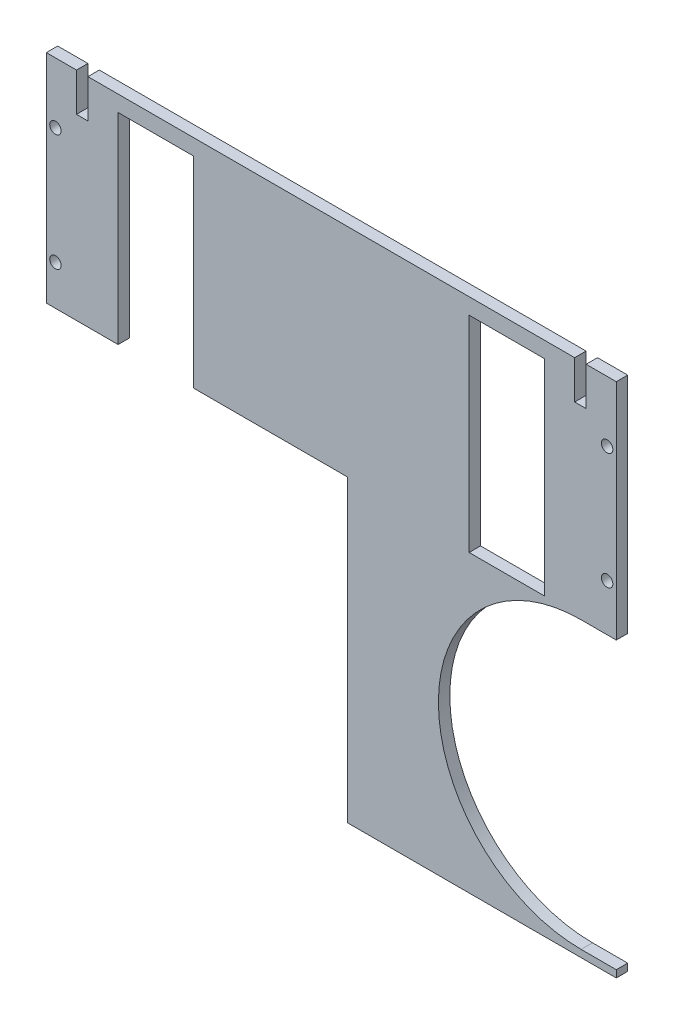
from build123d import *

# Parameters (mm, degrees)
SKETCH1_W           = 249.6
SKETCH1_H           = 267.4
SKETCH1_R           = 2.5
SKETCH1_W_2         = 33
SKETCH1_H_2         = 90
BOSS_EXTRUDE1_DEPTH = 5
CUT_EXTRUDE4_DEPTH  = 6
SKETCH7_W           = 5
SKETCH7_H           = 20
SKETCH7_H_2         = 25
CUT_EXTRUDE5_DEPTH  = 6


with BuildPart() as part:
    # Sketch1 → Boss-Extrude1 (new body)
    with BuildSketch(Plane.XY):
        with Locations((124.8, -202.7)):
            Rectangle(SKETCH1_W, SKETCH1_H)
        with Locations((245.6, -95.5)):
            Circle(SKETCH1_R, mode=Mode.SUBTRACT)
        with Locations((245.6, -146.5)):
            Circle(SKETCH1_R, mode=Mode.SUBTRACT)
        with Locations((4, -146.5)):
            Circle(SKETCH1_R, mode=Mode.SUBTRACT)
        with Locations((4, -95.5)):
            Circle(SKETCH1_R, mode=Mode.SUBTRACT)
        with Locations((201.66, -121)):
            Rectangle(SKETCH1_W_2, SKETCH1_H_2, mode=Mode.SUBTRACT)
        with Locations((47.94, -121)):
            Rectangle(SKETCH1_W_2, SKETCH1_H_2, mode=Mode.SUBTRACT)
    extrude(amount=BOSS_EXTRUDE1_DEPTH)

    # Sketch6 → Cut-Extrude4 (cut, through all)
    with BuildSketch(Plane.XY.offset(5)):
        Polygon((132, -295.148008477), (249.6, -295.148008477), (249.6, -336.4), (0, -336.4), (0, -227), (0, -164), (132, -164), align=None)
        with BuildLine():
            Line((234.205987928, -292), (296.705987928, -292))
            Line((296.705987928, -292), (296.705987928, -167))
            Line((296.705987928, -167), (234.205987928, -167))
            ThreePointArc((234.205987928, -167), (171.705987928, -229.5), (234.205987928, -292))
        make_face()
    extrude(amount=-CUT_EXTRUDE4_DEPTH, mode=Mode.SUBTRACT)

    # Sketch7 → Cut-Extrude5 (cut, through all)
    with BuildSketch(Plane.XY.offset(5)):
        with Locations((15.72, -30.8123203)):
            Rectangle(SKETCH7_W, SKETCH7_H)
        with Locations((233.88, -30.8123203)):
            Rectangle(SKETCH7_W, SKETCH7_H)
        with Locations((15.72, -73.3123203)):
            Rectangle(SKETCH7_W, SKETCH7_H_2)
        with Locations((233.88, -73.3123203)):
            Rectangle(SKETCH7_W, SKETCH7_H_2)
    extrude(amount=-CUT_EXTRUDE5_DEPTH, mode=Mode.SUBTRACT)


solid = part.part
